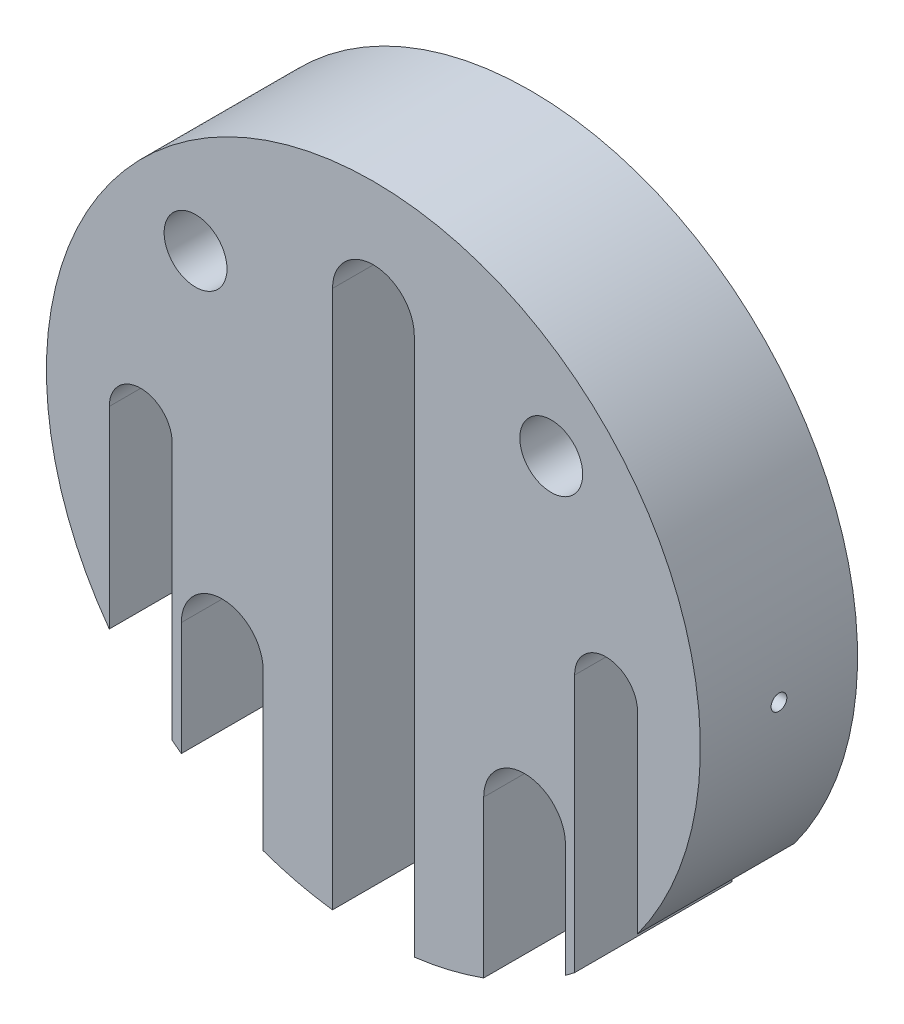
from build123d import *

# Parameters (mm, degrees)
SKETCH1_R              = 52
BOSS_EXTRUDE1_DEPTH    = 25
CUT_EXTRUDE1_DEPTH     = 25
SKETCH3_R              = 6.5
CUT_EXTRUDE2_DEPTH     = 30
SKETCH5_R              = 6.5
CUT_EXTRUDE3_DEPTH     = 30
SKETCH6_W              = 13
SKETCH6_H              = 90.106241662
SKETCH6_H_2            = 26.210700472
SKETCH6_H_3            = 29.761182449
CUT_EXTRUDE4_DEPTH     = 30
M3_TAPPED_HOLE1_REACH  = 120.933
M3_TAPPED_HOLE1_BORE_R = 1.25
SKETCH10_R             = 5
CUT_EXTRUDE5_DEPTH     = 30


with BuildPart() as part:
    # Sketch1 → Boss-Extrude1 (new body)
    with BuildSketch(Plane.XY):
        Circle(SKETCH1_R)
    extrude(amount=BOSS_EXTRUDE1_DEPTH)

    # Sketch2 → Cut-Extrude1 (cut)
    with BuildSketch(Plane.XY.offset(25)):
        with BuildLine():
            Line((32, 0), (32, -45))
            Line((32, -45), (42, -45))
            Line((42, -45), (42, 3.54e-07))
            ThreePointArc((42, 3.54e-07), (36.999999823, 5), (32, 0))
        make_face()
        with BuildLine():
            Line((-5, -39.999999646), (-5, -55))
            Line((-5, -55), (5, -55))
            Line((5, -55), (5, -40))
            ThreePointArc((5, -40), (1.77e-07, -35), (-5, -39.999999646))
        make_face()
        with BuildLine():
            Line((-32, -45), (-42, -45))
            Line((-42, -45), (-42, 3.54e-07))
            ThreePointArc((-42, 3.54e-07), (-36.999999823, 5), (-32, 0))
            Line((-32, 0), (-32, -45))
        make_face()
    extrude(amount=-CUT_EXTRUDE1_DEPTH, mode=Mode.SUBTRACT)

    # Sketch3 → Cut-Extrude2 (cut)
    with BuildSketch(Plane.XY.offset(25)):
        with Locations((0, 34)):
            Circle(SKETCH3_R)
    extrude(amount=-CUT_EXTRUDE2_DEPTH, mode=Mode.SUBTRACT)

    # Sketch5 → Cut-Extrude3 (cut)
    with BuildSketch(Plane.XY.offset(25)):
        with Locations((-24.04163056, -24.04163056)):
            Circle(SKETCH5_R)
    cut_extrude3 = extrude(amount=-CUT_EXTRUDE3_DEPTH, mode=Mode.SUBTRACT)

    # Mirror1: Cut-Extrude3 across plane
    add(cut_extrude3.mirror(Plane(origin=(0, 0, 0), x_dir=(0, 0, 1), z_dir=(1, 0, 0))), mode=Mode.SUBTRACT)

    # Sketch6 → Cut-Extrude4 (cut)
    with BuildSketch(Plane.XY.offset(25)):
        with Locations((0, -11.053120831)):
            Rectangle(SKETCH6_W, SKETCH6_H)
        with Locations((24.04163056, -37.146980796)):
            Rectangle(SKETCH6_W, SKETCH6_H_2)
        with Locations((-24.04163056, -38.922221785)):
            Rectangle(SKETCH6_W, SKETCH6_H_3)
    extrude(amount=-CUT_EXTRUDE4_DEPTH, mode=Mode.SUBTRACT)

    # M3 Tapped Hole1 bore → M3 Tapped Hole1 (cut, up to next)
    with BuildSketch(Plane.ZY.offset(52), mode=Mode.PRIVATE) as m3_tapped_hole1_sk1:
        with Locations((12.5, 0)):
            Circle(M3_TAPPED_HOLE1_BORE_R)
    m3_tapped_hole1_tool1 = extrude(m3_tapped_hole1_sk1.sketch, amount=-M3_TAPPED_HOLE1_REACH, mode=Mode.PRIVATE) & part.part
    m3_tapped_hole1 = m3_tapped_hole1_tool1.solids().sort_by_distance((-52, 0, 12.5))[0]
    add(m3_tapped_hole1, mode=Mode.SUBTRACT)

    # Mirror2: M3 Tapped Hole1 across plane
    add(m3_tapped_hole1.mirror(Plane(origin=(0, 0, 0), x_dir=(0, 0, 1), z_dir=(1, 0, 0))), mode=Mode.SUBTRACT)

    # Sketch10 → Cut-Extrude5 (cut)
    with BuildSketch(Plane.XY.offset(25)):
        with Locations((28.284271247, 28.284271247)):
            Circle(SKETCH10_R)
    cut_extrude5 = extrude(amount=-CUT_EXTRUDE5_DEPTH, mode=Mode.SUBTRACT)

    # Mirror3: Cut-Extrude5 across plane
    add(cut_extrude5.mirror(Plane(origin=(0, 0, 0), x_dir=(0, 0, 1), z_dir=(1, 0, 0))), mode=Mode.SUBTRACT)


solid = part.part
